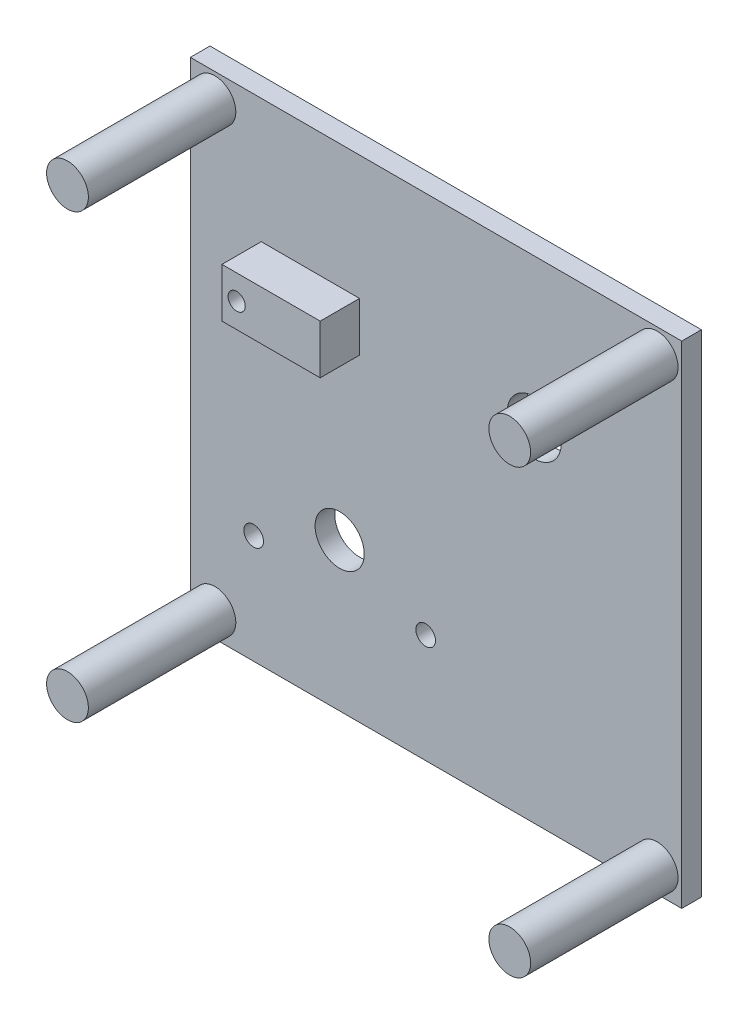
from build123d import *

# Parameters (mm, degrees)
SKETCH1_W               = 100
SKETCH1_H               = 100
BOSS_EXTRUDE1_DEPTH     = 4
SKETCH2_R               = 4.25
BOSS_EXTRUDE2_DEPTH     = 30
SKETCH4_R               = 4.75
CUT_EXTRUDE1_DEPTH      = 1.5
SKETCH5_R               = 2
SKETCH5_R_2             = 5
CUT_EXTRUDE2_DEPTH      = 31
CUT_EXTRUDE2_DEPTH_BACK = 5
SKETCH6_W               = 20
SKETCH6_H               = 10
SKETCH6_R               = 1.75
BOSS_EXTRUDE3_DEPTH     = 8
SKETCH7_R               = 5.5
CUT_EXTRUDE3_DEPTH      = 8


with BuildPart() as part:
    # Sketch1 → Boss-Extrude1 (new body)
    with BuildSketch(Plane.XY):
        Rectangle(SKETCH1_W, SKETCH1_H)
    extrude(amount=BOSS_EXTRUDE1_DEPTH)

    # Sketch2 → Boss-Extrude2 (add)
    with BuildSketch(Plane.XY.offset(4)):
        with Locations((45, 45)):
            Circle(SKETCH2_R)
        with Locations((-45, 45)):
            Circle(SKETCH2_R)
        with Locations((-45, -45)):
            Circle(SKETCH2_R)
        with Locations((45, -45)):
            Circle(SKETCH2_R)
    extrude(amount=BOSS_EXTRUDE2_DEPTH)

    # Sketch4 → Cut-Extrude1 (cut)
    with BuildSketch(Plane(origin=(0, 0, 0), x_dir=(-1, 0, 0), z_dir=(0, 0, -1))):
        with Locations((-45, 45)):
            Circle(SKETCH4_R)
        with Locations((45, 45)):
            Circle(SKETCH4_R)
        with Locations((-45, -45)):
            Circle(SKETCH4_R)
        with Locations((45, -45)):
            Circle(SKETCH4_R)
    extrude(amount=-CUT_EXTRUDE1_DEPTH, mode=Mode.SUBTRACT)

    # Sketch5 → Cut-Extrude2 (cut, two sides)
    with BuildSketch(Plane(origin=(-38.404344239, -79.614153906, 4), x_dir=(1, 0, 0), z_dir=(0, 0, 1))) as cut_extrude2_sk:
        with Locations((36.292632212, 51.750208167)):
            Circle(SKETCH5_R)
        with Locations((1.292632212, 51.750208167)):
            Circle(SKETCH5_R)
        with Locations((18.792632212, 59.750208167)):
            Circle(SKETCH5_R_2)
    extrude(amount=CUT_EXTRUDE2_DEPTH, mode=Mode.SUBTRACT)
    extrude(cut_extrude2_sk.sketch, amount=-CUT_EXTRUDE2_DEPTH_BACK, mode=Mode.SUBTRACT)

    # Sketch6 → Boss-Extrude3 (add)
    with BuildSketch(Plane.XY.offset(4)):
        with Locations((-25.571153041, 19.73100851)):
            Rectangle(SKETCH6_W, SKETCH6_H)
        with Locations((-32.571153041, 19.73100851)):
            Circle(SKETCH6_R, mode=Mode.SUBTRACT)
    extrude(amount=BOSS_EXTRUDE3_DEPTH)

    # Sketch7 → Cut-Extrude3 (cut)
    with BuildSketch(Plane(origin=(-38.404344239, -79.614153906, 0), x_dir=(-1, 0, 0), z_dir=(0, 0, -1))):
        with Locations((-58.387586461, 99.345162416)):
            Circle(SKETCH7_R)
    extrude(amount=-CUT_EXTRUDE3_DEPTH, mode=Mode.SUBTRACT)


solid = part.part
